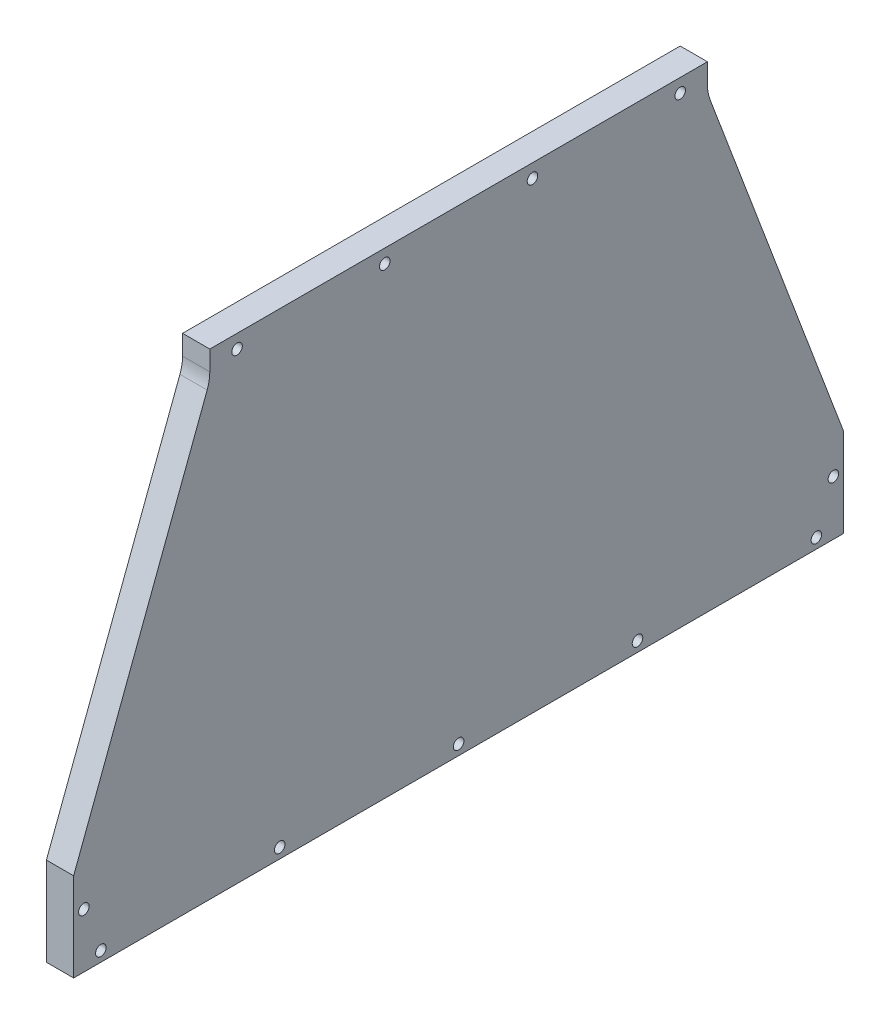
from build123d import *

# Parameters (mm, degrees)
BOSS_EXTRUDE1_DEPTH          = 12.7
FILLET1_R                    = 19.05
F_10_0_1935_DIAMETER_HOLE1_D = 4.9149


with BuildPart() as part:
    # Sketch1 → Boss-Extrude1 (new body)
    with BuildSketch(Plane.ZY.offset(152.399999331)):
        Polygon((179.525, -30.525), (179.525, 10.75), (116.025, 179.025), (116.025, 191.725), (-116.025, 191.725), (-116.025, 179.025), (-179.525, 10.75), (-179.525, -30.525), align=None)
    extrude(amount=BOSS_EXTRUDE1_DEPTH)

    # Fillet1
    fillet1_edges = [part.edges().sort_by_distance(p)[0] for p in [
        (-158.749999331, 179.025, -116.025),
        (-158.749999331, 179.025, 116.025),
    ]]
    fillet(fillet1_edges, radius=FILLET1_R)

    # #10 (0.1935) Diameter Hole1 (through all)
    with Locations(Plane.ZY.offset(165.099999331)):
        with Locations((-103.325, 185.375), (-34.441666667, 185.375), (34.441666667, 185.375), (103.325, 185.375), (174.7625, -5.125), (-174.7625, -5.125), (-166.825, -25.7625), (166.825, -25.7625), (0, -25.7625), (83.4125, -25.7625), (-83.4125, -25.7625)):
            Hole(F_10_0_1935_DIAMETER_HOLE1_D / 2)


solid = part.part
